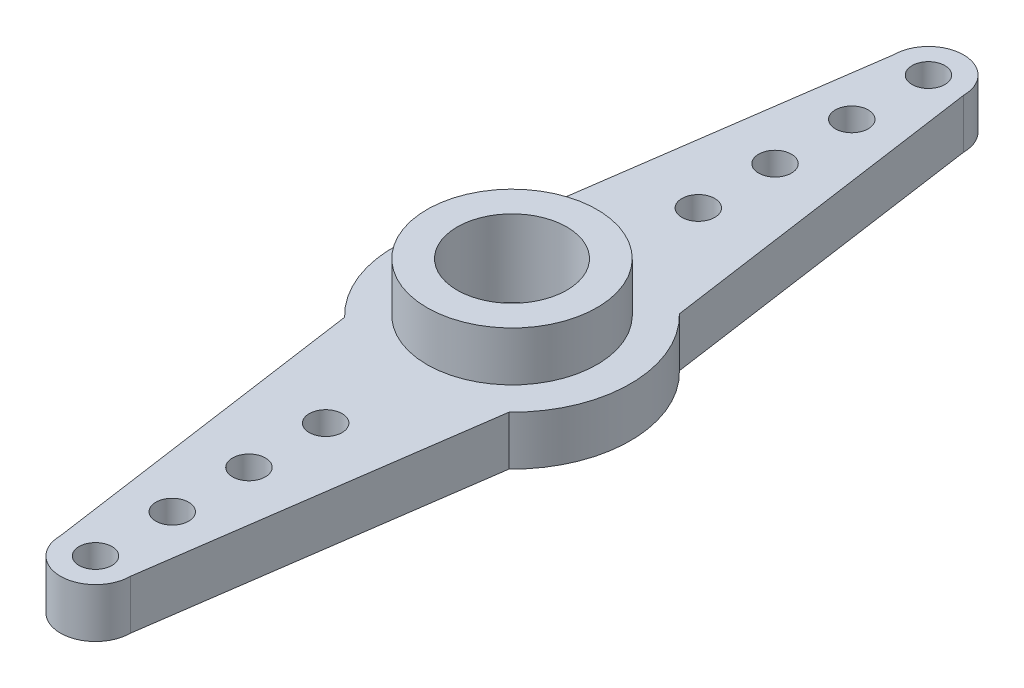
from build123d import *

# Parameters (mm, degrees)
SKETCH1_R           = 2.5
SKETCH1_R_2         = 0.75
BOSS_EXTRUDE1_DEPTH = 2.25
SKETCH2_R           = 3.879501895
SKETCH2_R_2         = 2.5
BOSS_EXTRUDE2_DEPTH = 2.25
SKETCH3_R           = 2.5
SKETCH3_R_2         = 2.008527967
BOSS_EXTRUDE3_DEPTH = 1
SKETCH4_R           = 3.8
SKETCH4_R_2         = 3
CUT_EXTRUDE1_DEPTH  = 0.5


with BuildPart() as part:
    # Sketch1 → Boss-Extrude1 (new body)
    with BuildSketch(Plane(origin=(0, 0, 0), x_dir=(1, 0, 0), z_dir=(0, 1, 0))):
        with BuildLine():
            Line((-1.6, 19), (-3.75, 3.885550154))
            ThreePointArc((-3.75, 3.885550154), (-5.4, 0), (-3.75, -3.885550154))
            Line((-3.75, -3.885550154), (-1.6, -19))
            ThreePointArc((-1.6, -19), (0, -20.6), (1.6, -19))
            Line((1.6, -19), (3.75, -3.885550154))
            ThreePointArc((3.75, -3.885550154), (5.4, 0), (3.75, 3.885550154))
            Line((3.75, 3.885550154), (1.6, 19))
            ThreePointArc((1.6, 19), (0, 20.6), (-1.6, 19))
        make_face()
        Circle(SKETCH1_R, mode=Mode.SUBTRACT)
        with Locations((0, -19)):
            Circle(SKETCH1_R_2, mode=Mode.SUBTRACT)
        with Locations((0, 19)):
            Circle(SKETCH1_R_2, mode=Mode.SUBTRACT)
        with Locations((0, 15.5)):
            Circle(SKETCH1_R_2, mode=Mode.SUBTRACT)
        with Locations((0, 12)):
            Circle(SKETCH1_R_2, mode=Mode.SUBTRACT)
        with Locations((0, 8.5)):
            Circle(SKETCH1_R_2, mode=Mode.SUBTRACT)
        with Locations((0, -15.5)):
            Circle(SKETCH1_R_2, mode=Mode.SUBTRACT)
        with Locations((0, -12)):
            Circle(SKETCH1_R_2, mode=Mode.SUBTRACT)
        with Locations((0, -8.5)):
            Circle(SKETCH1_R_2, mode=Mode.SUBTRACT)
    extrude(amount=BOSS_EXTRUDE1_DEPTH)

    # Sketch2 → Boss-Extrude2 (add)
    with BuildSketch(Plane(origin=(0, 2.25, 0), x_dir=(1, 0, 0), z_dir=(0, 1, 0))):
        Circle(SKETCH2_R)
        Circle(SKETCH2_R_2, mode=Mode.SUBTRACT)
    extrude(amount=BOSS_EXTRUDE2_DEPTH)

    # Sketch3 → Boss-Extrude3 (add)
    with BuildSketch(Plane.XZ):
        Circle(SKETCH3_R)
        Circle(SKETCH3_R_2, mode=Mode.SUBTRACT)
    extrude(amount=-BOSS_EXTRUDE3_DEPTH)

    # Sketch4 → Cut-Extrude1 (cut)
    with BuildSketch(Plane.XZ):
        Circle(SKETCH4_R)
        Circle(SKETCH4_R_2, mode=Mode.SUBTRACT)
    extrude(amount=-CUT_EXTRUDE1_DEPTH, mode=Mode.SUBTRACT)


solid = part.part
